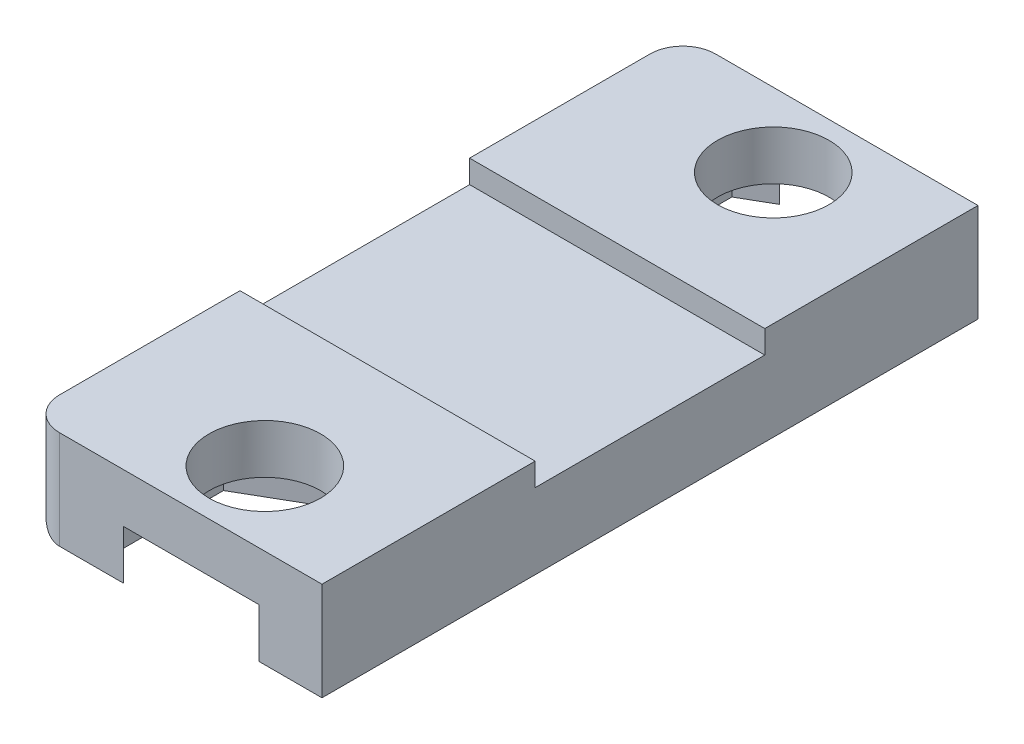
from build123d import *

# Parameters (mm, degrees)
CROQUIS1_W              = 9
CROQUIS1_H              = 20
CROQUIS1_R              = 1.7
SALIENTE_EXTRUIR1_DEPTH = 3
CORTAR_EXTRUIR2_DEPTH   = 1.5
CORTAR_EXTRUIR3_REACH   = 11
CROQUIS3_W              = 7
CROQUIS3_H              = 1
REDONDEO1_R             = 1
CROQUIS4_W              = 9
CROQUIS4_H              = 7
SALIENTE_EXTRUIR2_DEPTH = 0.3


with BuildPart() as part:
    # Croquis1 → Saliente-Extruir1 (new body)
    with BuildSketch(Plane(origin=(0, 0, 0), x_dir=(1, 0, 0), z_dir=(0, 1, 0))):
        with Locations((165.454426616, -12)):
            Rectangle(CROQUIS1_W, CROQUIS1_H)
        with Locations((165.962302832, -4.25)):
            Circle(CROQUIS1_R, mode=Mode.SUBTRACT)
        with Locations((165.962302832, -19.75)):
            Circle(CROQUIS1_R, mode=Mode.SUBTRACT)
    extrude(amount=-SALIENTE_EXTRUIR1_DEPTH)

    # Croquis2 → Cortar-Extruir2 (cut)
    with BuildSketch(Plane.XZ.offset(3)):
        Polygon((168.943819954, 21.471379713), (165.962302832, 23.192759426), (162.98078571, 21.471379713), (162.98078571, 18.028620287), (165.962302832, 16.307240574), (168.943819954, 18.028620287), align=None)
        Polygon((168.943819954, 5.971379713), (168.943819954, 2.528620287), (165.962302832, 0.807240574), (162.98078571, 2.528620287), (162.98078571, 5.971379713), (165.962302832, 7.692759426), align=None)
    extrude(amount=-CORTAR_EXTRUIR2_DEPTH, mode=Mode.SUBTRACT)

    # Croquis3 → Cortar-Extruir3 (cut, up to next)
    with BuildSketch(Plane.ZY.offset(-160.954426616), mode=Mode.PRIVATE) as cortar_extruir3_sk1:
        with Locations((12, -0.5)):
            Rectangle(CROQUIS3_W, CROQUIS3_H)
    cortar_extruir3_tool1 = extrude(cortar_extruir3_sk1.sketch, amount=-CORTAR_EXTRUIR3_REACH, mode=Mode.PRIVATE) & part.part
    add(cortar_extruir3_tool1.solids().sort_by_distance((160.954427, -0.5, 12))[0], mode=Mode.SUBTRACT)

    # Redondeo1
    redondeo1_edges = [part.edges().sort_by_distance(p)[0] for p in [
        (160.954426616, -3, 12),
        (160.954426616, -1.5, 2),
        (160.954426616, -1.5, 22),
    ]]
    fillet(redondeo1_edges, radius=REDONDEO1_R)

    # Croquis4 → Saliente-Extruir2 (add)
    with BuildSketch(Plane(origin=(0, -1, 0), x_dir=(1, 0, 0), z_dir=(0, 1, 0))):
        with Locations((165.454426616, -12)):
            Rectangle(CROQUIS4_W, CROQUIS4_H)
    extrude(amount=SALIENTE_EXTRUIR2_DEPTH)


solid = part.part
